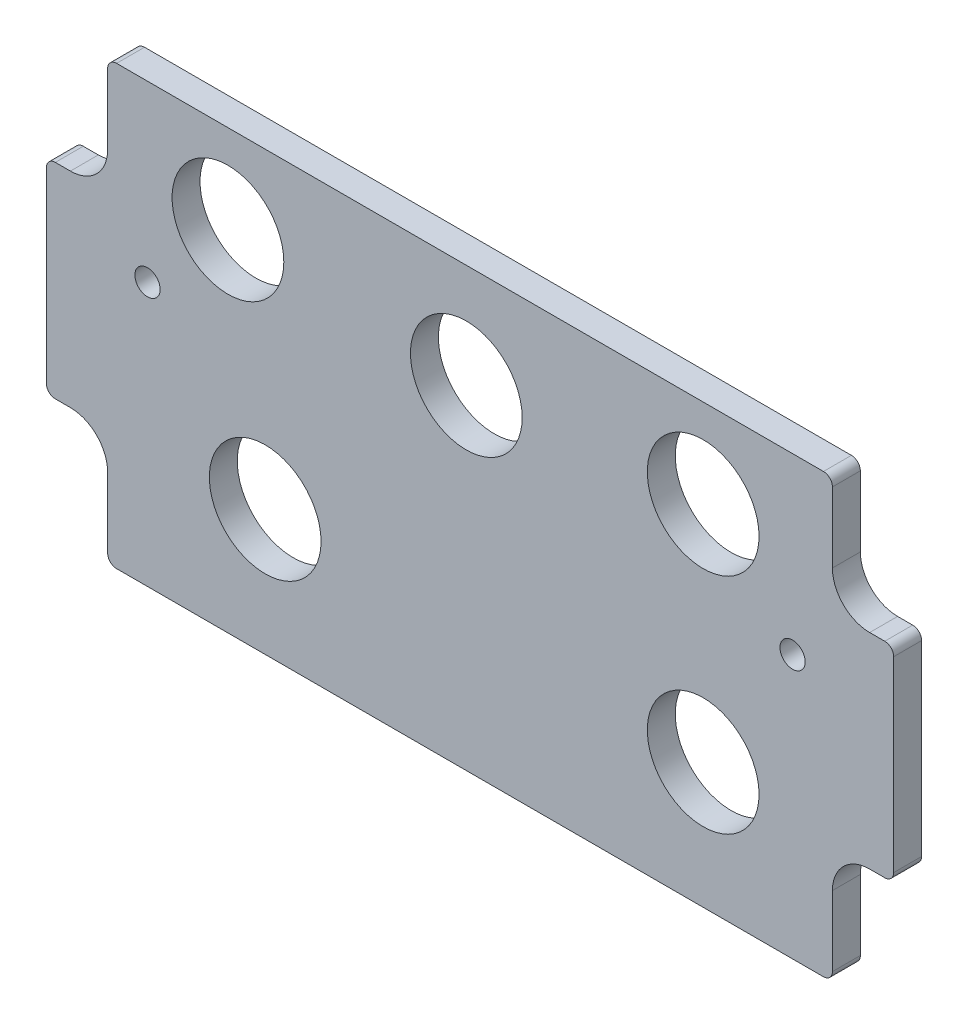
from build123d import *

# Parameters (mm, degrees)
BOSS_EXTRUDE1_DEPTH         = 4.7625
F_3_4_0_75_DIAMETER_HOLE1_D = 19.05
F_6_CLEARANCE_HOLE1_D       = 4.3053


with BuildPart() as part:
    # Sketch1 → Boss-Extrude1 (new body)
    with BuildSketch(Plane.XY):
        with BuildLine():
            Line((134.8105, 61.9125), (134.8105, 73.88225))
            ThreePointArc((134.8105, 73.88225), (134.364130735, 74.959880735), (133.2865, 75.40625))
            Line((133.2865, 75.40625), (12.7635, 75.40625))
            ThreePointArc((12.7635, 75.40625), (11.685869265, 74.959880735), (11.2395, 73.88225))
            Line((11.2395, 73.88225), (11.2395, 61.9125))
            ThreePointArc((11.2395, 61.9125), (9.379628061, 57.422371939), (4.8895, 55.5625))
            Line((4.8895, 55.5625), (2.31775, 55.5625))
            ThreePointArc((2.31775, 55.5625), (1.240119265, 55.116130735), (0.79375, 54.0385))
            Line((0.79375, 54.0385), (0.79375, 22.1615))
            ThreePointArc((0.79375, 22.1615), (1.240119265, 21.083869265), (2.31775, 20.6375))
            Line((2.31775, 20.6375), (4.8895, 20.6375))
            ThreePointArc((4.8895, 20.6375), (9.379628061, 18.777628061), (11.2395, 14.2875))
            Line((11.2395, 14.2875), (11.2395, 2.31775))
            ThreePointArc((11.2395, 2.31775), (11.685869265, 1.240119265), (12.7635, 0.79375))
            Line((12.7635, 0.79375), (133.2865, 0.79375))
            ThreePointArc((133.2865, 0.79375), (134.364130735, 1.240119265), (134.8105, 2.31775))
            Line((134.8105, 2.31775), (134.8105, 14.2875))
            ThreePointArc((134.8105, 14.2875), (136.670371939, 18.777628061), (141.1605, 20.6375))
            Line((141.1605, 20.6375), (143.73225, 20.6375))
            ThreePointArc((143.73225, 20.6375), (144.809880735, 21.083869265), (145.25625, 22.1615))
            Line((145.25625, 22.1615), (145.25625, 54.0385))
            ThreePointArc((145.25625, 54.0385), (144.809880735, 55.116130735), (143.73225, 55.5625))
            Line((143.73225, 55.5625), (141.1605, 55.5625))
            ThreePointArc((141.1605, 55.5625), (136.670371939, 57.422371939), (134.8105, 61.9125))
        make_face()
    extrude(amount=BOSS_EXTRUDE1_DEPTH)

    # 3/4 (0.75) Diameter Hole1 (through all)
    with Locations(Plane.XY.offset(4.7625)):
        with Locations((31.75, 60.325), (72.39, 57.658), (112.776, 60.325), (112.776, 22.225), (38.1, 22.225)):
            Hole(F_3_4_0_75_DIAMETER_HOLE1_D / 2)

    # #6 Clearance Hole1 (through all)
    with Locations(Plane.XY.offset(4.7625)):
        with Locations((18.034, 45.72), (128.016, 45.72)):
            Hole(F_6_CLEARANCE_HOLE1_D / 2)


solid = part.part
